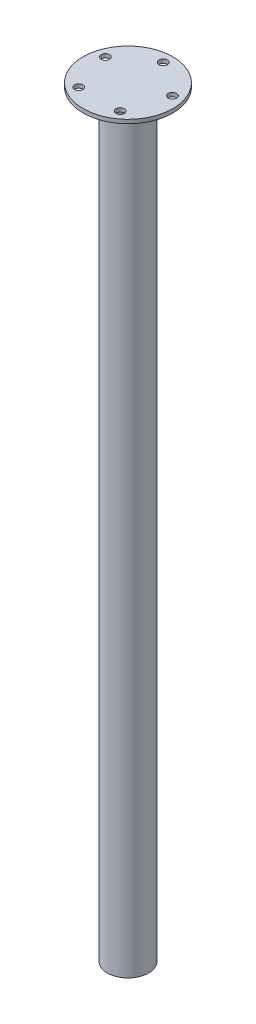
from build123d import *

# Parameters (mm, degrees)
SKETCH1_R           = 16
SKETCH1_R_2         = 14
BOSS_EXTRUDE1_DEPTH = 590
SKETCH2_R           = 35
BOSS_EXTRUDE2_DEPTH = 3
CHAMFER1_SIZE       = 2
SKETCH4_R           = 3.25
CUT_EXTRUDE2_DEPTH  = 594


with BuildPart() as part:
    # Sketch1 → Boss-Extrude1 (new body)
    with BuildSketch(Plane(origin=(0, 0, 0), x_dir=(1, 0, 0), z_dir=(0, 1, 0))):
        Circle(SKETCH1_R)
        Circle(SKETCH1_R_2, mode=Mode.SUBTRACT)
    extrude(amount=BOSS_EXTRUDE1_DEPTH)

    # Sketch2 → Boss-Extrude2 (add)
    with BuildSketch(Plane(origin=(0, 590, 0), x_dir=(1, 0, 0), z_dir=(0, 1, 0))):
        Circle(SKETCH2_R)
    extrude(amount=BOSS_EXTRUDE2_DEPTH)

    # Chamfer1
    chamfer1_edges = [part.edges().sort_by_distance(p)[0] for p in [
        (-16, 590, 0),
    ]]
    chamfer(chamfer1_edges, length=CHAMFER1_SIZE)

    # Sketch4 → Cut-Extrude2 (cut, through all)
    with BuildSketch(Plane(origin=(0, 593, 0), x_dir=(1, 0, 0), z_dir=(0, 1, 0))):
        with Locations((0, 27.5)):
            Circle(SKETCH4_R)
        with Locations((26.154054198, 8.497967345)):
            Circle(SKETCH4_R)
        with Locations((16.164094438, -22.247967345)):
            Circle(SKETCH4_R)
        with Locations((-16.164094438, -22.247967345)):
            Circle(SKETCH4_R)
        with Locations((-26.154054198, 8.497967345)):
            Circle(SKETCH4_R)
    extrude(amount=-CUT_EXTRUDE2_DEPTH, mode=Mode.SUBTRACT)


solid = part.part
